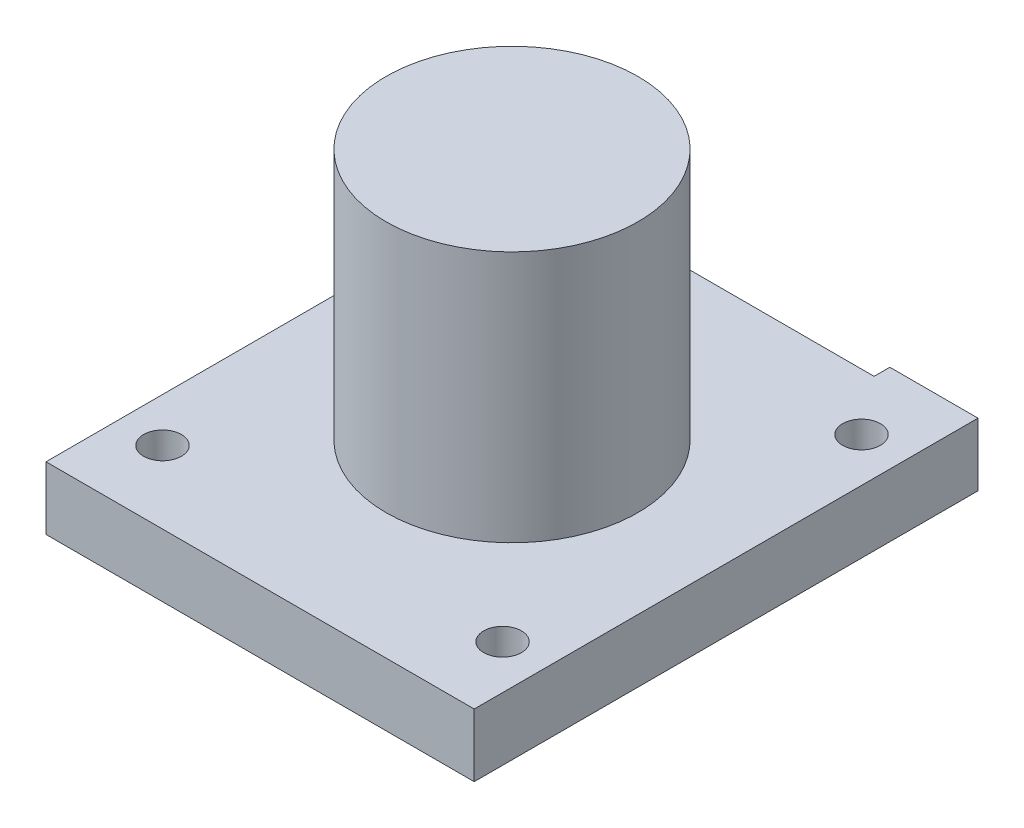
from build123d import *

# Parameters (mm, degrees)
SKETCH_1_R          = 10
EXTRUDE_1_DEPTH     = 20
EXTRUDE_START       = -5
SKETCH_4_R          = 10
EXTRUDE_3_DEPTH     = 5
EXTRUDE_START_2     = -3
SKETCH_4_4_R        = 10
EXTRUDE_4_DEPTH     = 3
SKETCH_5_R          = 1.5
CUT_EXTRUDE_1_DEPTH = 10


with BuildPart() as part:
    # 草图1 → 凸台-拉伸1 (new body)
    with BuildSketch(Plane(origin=(0, 0, 0), x_dir=(1, 0, 0), z_dir=(0, 1, 0))):
        with Locations((12, 12)):
            Circle(SKETCH_1_R)
    extrude(amount=EXTRUDE_1_DEPTH)

    # 草图4<4> → 凸台-拉伸4 (add)
    with BuildSketch(Plane(origin=(0, 0, 0), x_dir=(1, 0, 0), z_dir=(0, 1, 0)).offset(EXTRUDE_START_2)):
        with Locations((12, 12)):
            Circle(SKETCH_4_4_R)
    extrude(amount=EXTRUDE_4_DEPTH)


with BuildPart() as body_2:
    # 草图4 → 凸台-拉伸3 (new body)
    with BuildSketch(Plane(origin=(0, 0, 0), x_dir=(1, 0, 0), z_dir=(0, 1, 0)).offset(EXTRUDE_START)):
        Polygon((29, 32), (22, 32), (22, 30.75), (2, 30.75), (2, 32), (-5, 32), (-5, -8), (29, -8), align=None)
        with Locations((12, 12)):
            Circle(SKETCH_4_R, mode=Mode.SUBTRACT)
    extrude(amount=EXTRUDE_3_DEPTH)

    # 草图5 → 切除-拉伸1 (cut)
    with BuildSketch(Plane(origin=(0, 0, 0), x_dir=(1, 0, 0), z_dir=(0, 1, 0))):
        with Locations((-1.5, 26.25)):
            Circle(SKETCH_5_R)
        with Locations((-1.5, -2.25)):
            Circle(SKETCH_5_R)
        with Locations((25.5, -2.25)):
            Circle(SKETCH_5_R)
        with Locations((25.5, 26.25)):
            Circle(SKETCH_5_R)
    extrude(amount=-CUT_EXTRUDE_1_DEPTH, mode=Mode.SUBTRACT)


solid = Compound([part.part, body_2.part])
